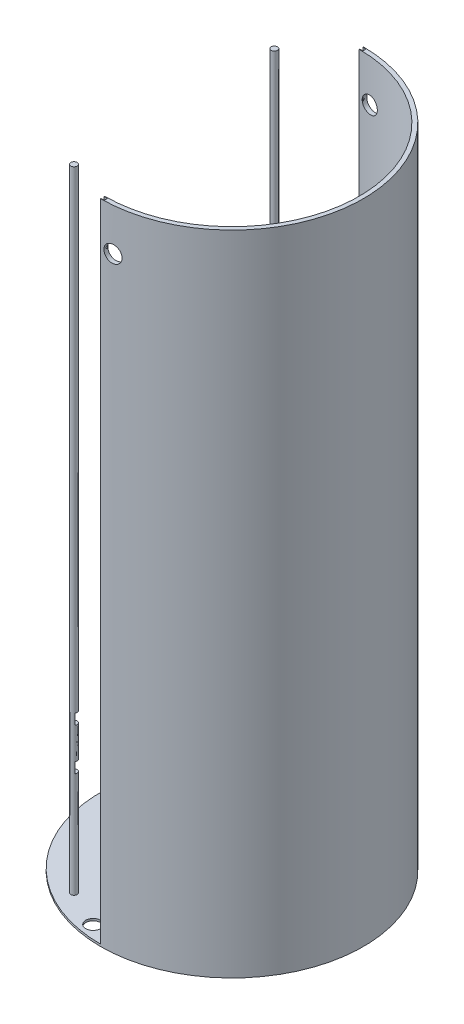
from build123d import *

# Parameters (mm, degrees)
SKETCH2_R               = 62.5
SKETCH2_R_2             = 0.75
BOSS_EXTRUDE1_DEPTH     = 1
SKETCH3_R               = 1.5
BOSS_EXTRUDE2_DEPTH     = 300
SKETCH5_W               = 3
SKETCH5_H               = 5
CUT_EXTRUDE1_DEPTH      = 5
CIRPATTERN1_COUNT       = 3
BOSS_EXTRUDE3_DEPTH     = 307
CUT_EXTRUDE2_REACH      = 322.432
SKETCH10_W              = 1.5
SKETCH10_H              = 1.5
SKETCH10_W_2            = 3
SKETCH11_R              = 3.5
CUT_EXTRUDE3_DEPTH      = 5
CIRPATTERN4_COUNT       = 2
CIRPATTERN4_ANGLE       = 80
MIRROR1_COPY_1_SKETCH_R = 3.5
MIRROR1_COPY_1_DEPTH    = 5
MIRROR1_COPY_2_SKETCH_R = 3.5
MIRROR1_COPY_2_DEPTH    = 5


with BuildPart() as part:
    # Sketch2 → Boss-Extrude1 (new body)
    with BuildSketch(Plane(origin=(0, 0, 0), x_dir=(1, 0, 0), z_dir=(0, 1, 0))):
        with Locations(Location((0, 0, 0), (0, 0, 270))):
            Circle(SKETCH2_R)
        with Locations(Location((0, 10, 0), (0, 0, 270))):
            Circle(SKETCH2_R_2, mode=Mode.SUBTRACT)
        with Locations(Location((8.660254038, -5, 0), (0, 0, 270))):
            Circle(SKETCH2_R_2, mode=Mode.SUBTRACT)
        with Locations(Location((-8.660254038, -5, 0), (0, 0, 270))):
            Circle(SKETCH2_R_2, mode=Mode.SUBTRACT)
    extrude(amount=BOSS_EXTRUDE1_DEPTH)

    # Sketch3 → Boss-Extrude2 (add)
    with BuildSketch(Plane(origin=(0, 1, 0), x_dir=(1, 0, 0), z_dir=(0, 1, 0))):
        with Locations(Location((55, 0, 0), (0, 0, 270))):
            Circle(SKETCH3_R)
    boss_extrude2 = extrude(amount=BOSS_EXTRUDE2_DEPTH)

    # Sketch5 → Cut-Extrude1 (cut)
    with BuildSketch(Plane(origin=(55, 0, 0), x_dir=(0, 0, -1), z_dir=(1, 0, 0))):
        with Locations((0, 53.5)):
            Rectangle(SKETCH5_W, SKETCH5_H)
        with Locations((0, 73.5)):
            Rectangle(SKETCH5_W, SKETCH5_H)
    cut_extrude1 = extrude(amount=-CUT_EXTRUDE1_DEPTH, mode=Mode.SUBTRACT)

    # CirPattern1: Boss-Extrude2, Cut-Extrude1 ×3 about axis
    cirpattern1_axis = Axis((0, 0, 0), (0, 1, 0))
    add([boss_extrude2.rotate(cirpattern1_axis, i * 360 / CIRPATTERN1_COUNT) for i in range(1, CIRPATTERN1_COUNT)])
    add([cut_extrude1.rotate(cirpattern1_axis, i * 360 / CIRPATTERN1_COUNT) for i in range(1, CIRPATTERN1_COUNT)], mode=Mode.SUBTRACT)

    # Sketch6 → Boss-Extrude3 (add)
    with BuildSketch(Plane(origin=(0, 1, 0), x_dir=(1, 0, 0), z_dir=(0, 1, 0))):
        with BuildLine():
            Line((0, 62.5), (0, 60.5))
            ThreePointArc((0, 60.5), (60.5, 0), (0, -60.5))
            Line((0, -60.5), (0, -62.5))
            ThreePointArc((0, -62.5), (62.5, 0), (0, 62.5))
        make_face()
    extrude(amount=BOSS_EXTRUDE3_DEPTH)

    # Sketch10 → Cut-Extrude2 (cut, up to next)
    with BuildSketch(Plane(origin=(0, 308, 0), x_dir=(1, 0, 0), z_dir=(0, 1, 0)), mode=Mode.PRIVATE) as cut_extrude2_sk1:
        with Locations((0.75, -61.5)):
            Rectangle(SKETCH10_W, SKETCH10_H)
    cut_extrude2_tool1 = extrude(cut_extrude2_sk1.sketch, amount=-CUT_EXTRUDE2_REACH, mode=Mode.PRIVATE) & part.part
    # Sketch10 → Cut-Extrude2 (cut, up to next)
    with BuildSketch(Plane(origin=(0, 308, 0), x_dir=(1, 0, 0), z_dir=(0, 1, 0)), mode=Mode.PRIVATE) as cut_extrude2_sk2:
        with Locations((0, 61.5)):
            Rectangle(SKETCH10_W_2, SKETCH10_H)
    cut_extrude2_tool2 = extrude(cut_extrude2_sk2.sketch, amount=-CUT_EXTRUDE2_REACH, mode=Mode.PRIVATE) & part.part
    add(cut_extrude2_tool1.solids().sort_by_distance((0.75, 308, 61.5))[0], mode=Mode.SUBTRACT)
    add(cut_extrude2_tool2.solids().sort_by_distance((0, 308, -61.5))[0], mode=Mode.SUBTRACT)

    # Sketch11 → Cut-Extrude3 (cut)
    with BuildSketch(Plane(origin=(0, 1, 0), x_dir=(1, 0, 0), z_dir=(0, 1, 0))):
        with Locations(Location((-57, 0, 0), (0, 0, 270))):
            Circle(SKETCH11_R)
    cut_extrude3 = extrude(amount=-CUT_EXTRUDE3_DEPTH, mode=Mode.SUBTRACT)

    # CirPattern4: Cut-Extrude3 ×2 about axis
    cirpattern4_axis = Axis((0, 1, 0), (0, 1, 0))
    for i in range(1, CIRPATTERN4_COUNT):
        add(cut_extrude3.rotate(cirpattern4_axis, i * CIRPATTERN4_ANGLE / (CIRPATTERN4_COUNT - 1)), mode=Mode.SUBTRACT)

    # Mirror1 copy 1 sketch → Mirror1 copy 1 (cut)
    with BuildSketch(Plane(origin=(0, 1, 0), x_dir=(0.17364817766692714, 0, 0.9848077530122086), z_dir=(0, 1, 0))):
        with Locations((-57, 0)):
            Circle(MIRROR1_COPY_1_SKETCH_R)
    extrude(amount=-MIRROR1_COPY_1_DEPTH, mode=Mode.SUBTRACT)

    # Mirror1 copy 2 sketch → Mirror1 copy 2 (cut)
    with BuildSketch(Plane(origin=(0, 1, 0), x_dir=(1, 0, 0), z_dir=(0, 1, 0))):
        with Locations((-57, 0)):
            Circle(MIRROR1_COPY_2_SKETCH_R)
    extrude(amount=-MIRROR1_COPY_2_DEPTH, mode=Mode.SUBTRACT)

    # Sketch16 → CBORE for #6 Binding Head Machine Screw1 (revolve, cut)
    with BuildSketch(Plane(origin=(5.561206614, 287.931721959, 62.252092182), x_dir=(0.9960334749074581, 0, -0.08897930581755542), z_dir=(0, 1, 0))):
        Polygon((0, 0), (0, 8.293442612), (2.15265, 7), (2.15265, 2.2098), (3.96875, 2.2098), (3.96875, 0), align=None)
    cbore_for_6_binding_head_machine_screw1 = revolve(axis=Axis((6.126225206, 287.931721959, 68.576904747), (-0.08897930581755542, 0, -0.9960334749074581)), mode=Mode.SUBTRACT)

    # Mirror3: CBORE for #6 Binding Head Machine Screw1 across plane
    add(cbore_for_6_binding_head_machine_screw1.mirror(Plane.XY), mode=Mode.SUBTRACT)


solid = part.part
